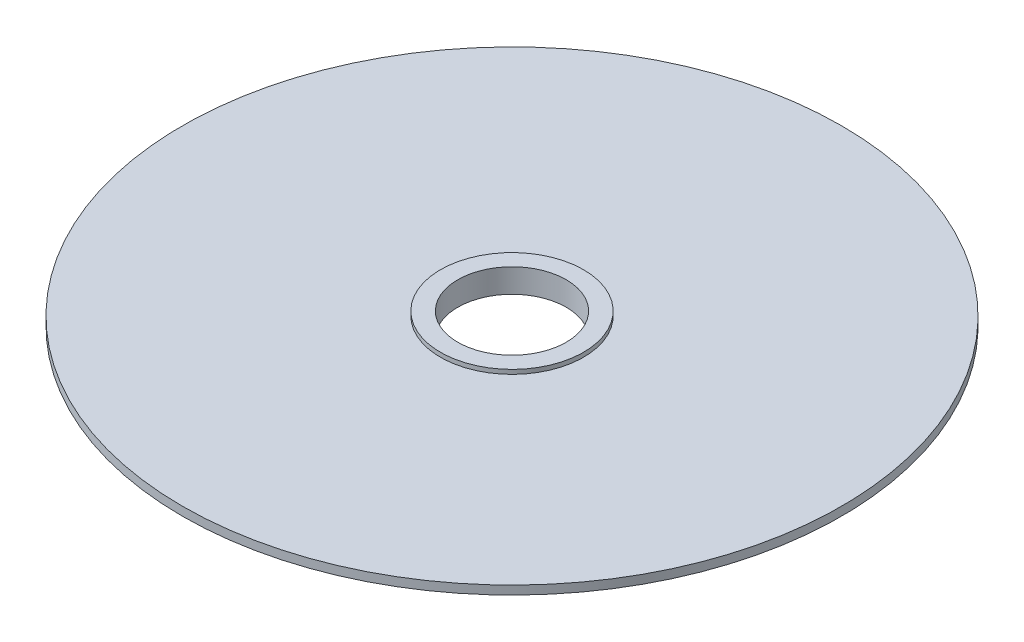
from build123d import *


with BuildPart() as part:
    # Sketch1 → Revolve1 (revolve)
    with BuildSketch(Plane.XY):
        Polygon((4, -1.6), (7.6, -1.6), (7.6, -1.4), (1.65, -1.4), (1.65, -1.3), (1.25, -1.3), (1.25, -1.85), (3.75, -1.85), align=None)
    revolve(axis=Axis((0, -1.3, 0), (0, -1, 0)))


solid = part.part
